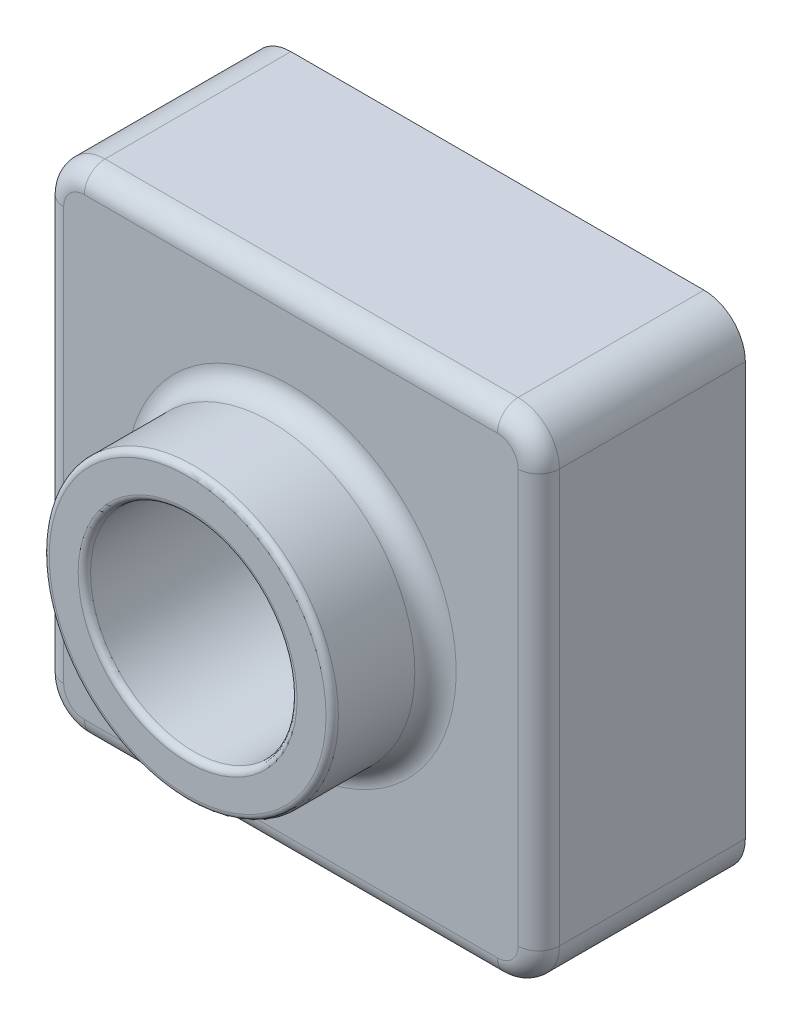
from build123d import *

# Parameters (mm, degrees)
SKETCH2_W           = 120
SKETCH2_H           = 120
BOSS_EXTRUDE1_DEPTH = 50
SKETCH4_R           = 35
BOSS_EXTRUDE2_DEPTH = 25
SKETCH6_R           = 25
CUT_EXTRUDE1_DEPTH  = 76
FILLET1_R           = 10
FILLET2_R           = 1.5
FILLET3_R           = 5
SHELL1_T            = -2


with BuildPart() as part:
    # Sketch2 → Boss-Extrude1 (new body)
    with BuildSketch(Plane.XY):
        with Locations((60, 60)):
            Rectangle(SKETCH2_W, SKETCH2_H)
    extrude(amount=BOSS_EXTRUDE1_DEPTH)

    # Sketch4 → Boss-Extrude2 (add)
    with BuildSketch(Plane.XY.offset(50)):
        with Locations((60, 60)):
            Circle(SKETCH4_R)
    extrude(amount=BOSS_EXTRUDE2_DEPTH)

    # Sketch6 → Cut-Extrude1 (cut, through all)
    with BuildSketch(Plane.XY.offset(75)):
        with Locations((60, 60)):
            Circle(SKETCH6_R)
    extrude(amount=-CUT_EXTRUDE1_DEPTH, mode=Mode.SUBTRACT)

    # Fillet1
    fillet1_edges = [part.edges().sort_by_distance(p)[0] for p in [
        (0, 120, 25),
        (120, 120, 25),
        (120, 0, 25),
        (0, 0, 25),
    ]]
    fillet(fillet1_edges, radius=FILLET1_R)

    # Fillet2
    fillet2_edges = [part.edges().sort_by_distance(p)[0] for p in [
        (25, 60, 75),
        (35, 60, 75),
    ]]
    fillet(fillet2_edges, radius=FILLET2_R)

    # Fillet3
    fillet3_edges = [part.edges().sort_by_distance(p)[0] for p in [
        (25, 60, 50),
        (0, 60, 50),
        (60, 120, 50),
        (60, 0, 50),
        (120, 60, 50),
        (117.071067812, 117.071067812, 50),
        (117.071067812, 2.928932188, 50),
        (2.928932188, 2.928932188, 50),
        (2.928932188, 117.071067812, 50),
    ]]
    fillet(fillet3_edges, radius=FILLET3_R)

    # Shell1
    shell1_openings = [part.faces().sort_by_distance(p)[0] for p in [
        (85, 60, 0),
    ]]
    offset(amount=SHELL1_T, openings=shell1_openings, kind=Kind.INTERSECTION)


solid = part.part
